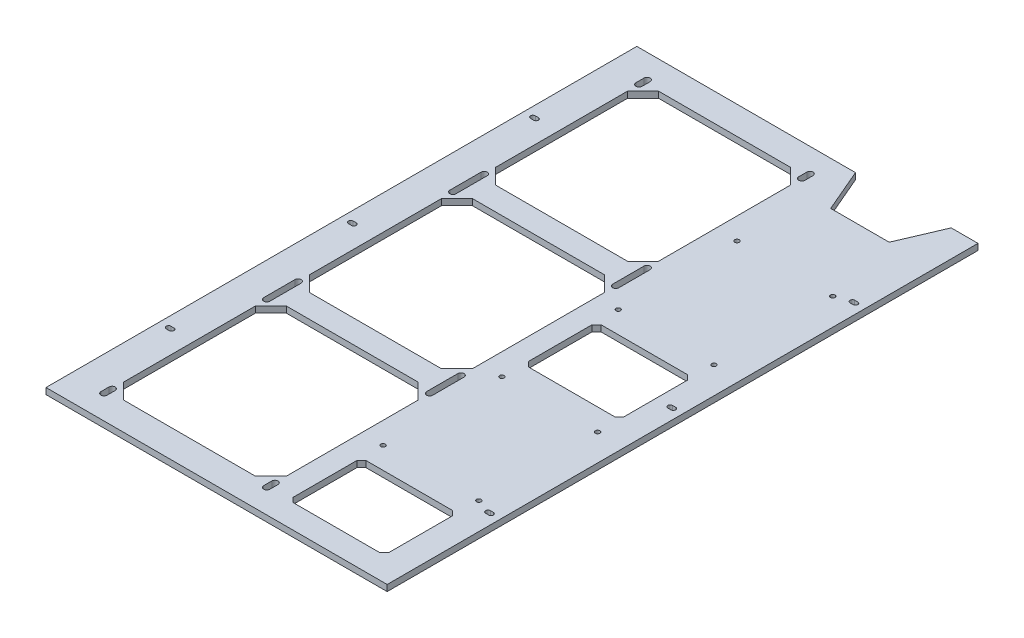
from build123d import *

# Parameters (mm, degrees)
SKETCH_1_R      = 1.45
EXTRUDE_1_DEPTH = 4


with BuildPart() as part:
    # 草圖1 → 填料-伸長1 (new body)
    with BuildSketch(Plane(origin=(0, 4, 0), x_dir=(1, 0, 0), z_dir=(0, 1, 0))):
        Polygon((110, 190.5), (92.72, 190.5), (80.72, 162.5), (43, 162.5), (31, 190.5), (-110, 190.5), (-110, -190.5), (110, -190.5), align=None)
        with Locations((31, 114.1)):
            Circle(SKETCH_1_R, mode=Mode.SUBTRACT)
        with Locations((92.72, 114.1)):
            Circle(SKETCH_1_R, mode=Mode.SUBTRACT)
        with Locations((31, 37.5)):
            Circle(SKETCH_1_R, mode=Mode.SUBTRACT)
        with Locations((92.72, 37.5)):
            Circle(SKETCH_1_R, mode=Mode.SUBTRACT)
        with Locations((31, -37.5)):
            Circle(SKETCH_1_R, mode=Mode.SUBTRACT)
        with Locations((92.72, -37.5)):
            Circle(SKETCH_1_R, mode=Mode.SUBTRACT)
        with Locations((31, -114.1)):
            Circle(SKETCH_1_R, mode=Mode.SUBTRACT)
        with Locations((92.72, -114.1)):
            Circle(SKETCH_1_R, mode=Mode.SUBTRACT)
        with BuildLine():
            Line((-104, 1.5), (-102, 1.5))
            ThreePointArc((-102, 1.5), (-100.5, 0), (-102, -1.5))
            Line((-102, -1.5), (-104, -1.5))
            ThreePointArc((-104, -1.5), (-105.5, 0), (-104, 1.5))
        make_face(mode=Mode.SUBTRACT)
        with BuildLine():
            Line((102, -116), (104, -116))
            ThreePointArc((104, -116), (105.5, -117.5), (104, -119))
            Line((104, -119), (102, -119))
            ThreePointArc((102, -119), (100.5, -117.5), (102, -116))
        make_face(mode=Mode.SUBTRACT)
        with BuildLine():
            Line((102, 1.5), (104, 1.5))
            ThreePointArc((104, 1.5), (105.5, 0), (104, -1.5))
            Line((104, -1.5), (102, -1.5))
            ThreePointArc((102, -1.5), (100.5, 0), (102, 1.5))
        make_face(mode=Mode.SUBTRACT)
        with BuildLine():
            Line((102, 119), (104, 119))
            ThreePointArc((104, 119), (105.5, 117.5), (104, 116))
            Line((104, 116), (102, 116))
            ThreePointArc((102, 116), (100.5, 117.5), (102, 119))
        make_face(mode=Mode.SUBTRACT)
        with BuildLine():
            Line((-104, -116), (-102, -116))
            ThreePointArc((-102, -116), (-100.5, -117.5), (-102, -119))
            Line((-102, -119), (-104, -119))
            ThreePointArc((-104, -119), (-105.5, -117.5), (-104, -116))
        make_face(mode=Mode.SUBTRACT)
        with BuildLine():
            Line((-104, 119), (-102, 119))
            ThreePointArc((-102, 119), (-100.5, 117.5), (-102, 116))
            Line((-102, 116), (-104, 116))
            ThreePointArc((-104, 116), (-105.5, 117.5), (-104, 119))
        make_face(mode=Mode.SUBTRACT)
        with BuildLine():
            Line((-90, -175.1), (-90, -169.9))
            ThreePointArc((-90, -169.9), (-88, -167.9), (-86, -169.9))
            Line((-86, -169.9), (-86, -175.1))
            ThreePointArc((-86, -175.1), (-88, -177.1), (-90, -175.1))
        make_face(mode=Mode.SUBTRACT)
        with BuildLine():
            Line((15, -70.1), (15, -49.9))
            ThreePointArc((15, -49.9), (17, -47.9), (19, -49.9))
            Line((19, -49.9), (19, -70.1))
            ThreePointArc((19, -70.1), (17, -72.1), (15, -70.1))
        make_face(mode=Mode.SUBTRACT)
        with BuildLine():
            Line((-90, -70.1), (-90, -49.9))
            ThreePointArc((-90, -49.9), (-88, -47.9), (-86, -49.9))
            Line((-86, -49.9), (-86, -70.1))
            ThreePointArc((-86, -70.1), (-88, -72.1), (-90, -70.1))
        make_face(mode=Mode.SUBTRACT)
        with BuildLine():
            Line((19, 175.1), (19, 169.9))
            ThreePointArc((19, 169.9), (17, 167.9), (15, 169.9))
            Line((15, 169.9), (15, 175.1))
            ThreePointArc((15, 175.1), (17, 177.1), (19, 175.1))
        make_face(mode=Mode.SUBTRACT)
        Polygon((89.72, -23.5), (34, -23.5), (31, -20.5), (31, 20.5), (34, 23.5), (89.72, 23.5), (92.72, 20.5), (92.72, -20.5), align=None, mode=Mode.SUBTRACT)
        Polygon((89.72, -175.1), (34, -175.1), (31, -172.1), (31, -131.1), (34, -128.1), (89.72, -128.1), (92.72, -131.1), (92.72, -172.1), align=None, mode=Mode.SUBTRACT)
        Polygon((-78, -172.5), (-88, -162.5), (-88, -77.5), (-78, -67.5), (7, -67.5), (17, -77.5), (17, -162.5), (7, -172.5), align=None, mode=Mode.SUBTRACT)
        Polygon((-78, -52.5), (-88, -42.5), (-88, 42.5), (-78, 52.5), (7, 52.5), (17, 42.5), (17, -42.5), (7, -52.5), align=None, mode=Mode.SUBTRACT)
        with BuildLine():
            Line((-86, 70.1), (-86, 49.9))
            ThreePointArc((-86, 49.9), (-88, 47.9), (-90, 49.9))
            Line((-90, 49.9), (-90, 70.1))
            ThreePointArc((-90, 70.1), (-88, 72.1), (-86, 70.1))
        make_face(mode=Mode.SUBTRACT)
        with BuildLine():
            Line((19, 70.1), (19, 49.9))
            ThreePointArc((19, 49.9), (17, 47.9), (15, 49.9))
            Line((15, 49.9), (15, 70.1))
            ThreePointArc((15, 70.1), (17, 72.1), (19, 70.1))
        make_face(mode=Mode.SUBTRACT)
        with BuildLine():
            Line((19, -169.9), (19, -175.1))
            ThreePointArc((19, -175.1), (17, -177.1), (15, -175.1))
            Line((15, -175.1), (15, -169.9))
            ThreePointArc((15, -169.9), (17, -167.9), (19, -169.9))
        make_face(mode=Mode.SUBTRACT)
        with BuildLine():
            Line((-86, 175.1), (-86, 169.9))
            ThreePointArc((-86, 169.9), (-88, 167.9), (-90, 169.9))
            Line((-90, 169.9), (-90, 175.1))
            ThreePointArc((-90, 175.1), (-88, 177.1), (-86, 175.1))
        make_face(mode=Mode.SUBTRACT)
        Polygon((17, 162.5), (17, 77.5), (7, 67.5), (-78, 67.5), (-88, 77.5), (-88, 162.5), (-78, 172.5), (7, 172.5), align=None, mode=Mode.SUBTRACT)
    extrude(amount=-EXTRUDE_1_DEPTH)


solid = part.part
